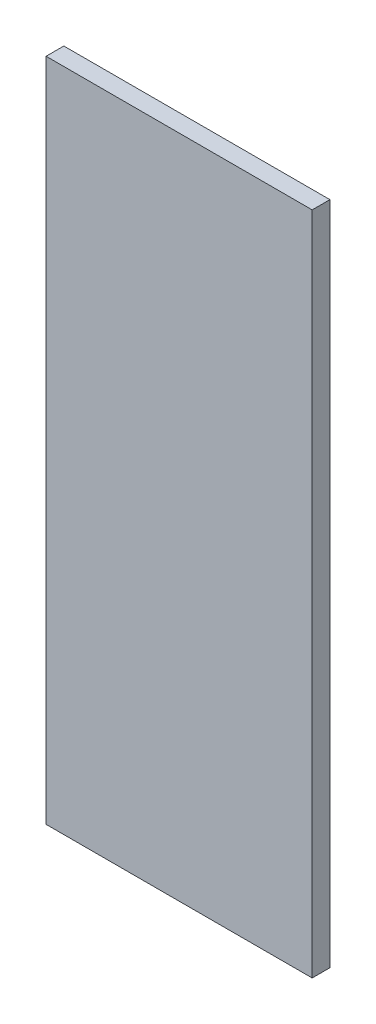
from build123d import *

# Parameters (mm, degrees)
SKETCH1_W           = 152.4
SKETCH1_H           = 10.16
BOSS_EXTRUDE1_DEPTH = 381


with BuildPart() as part:
    # Sketch1 → Boss-Extrude1 (new body)
    with BuildSketch(Plane(origin=(0, 0, 0), x_dir=(1, 0, 0), z_dir=(0, 1, 0))):
        with Locations((76.2, 5.08)):
            Rectangle(SKETCH1_W, SKETCH1_H)
    extrude(amount=BOSS_EXTRUDE1_DEPTH)


solid = part.part
